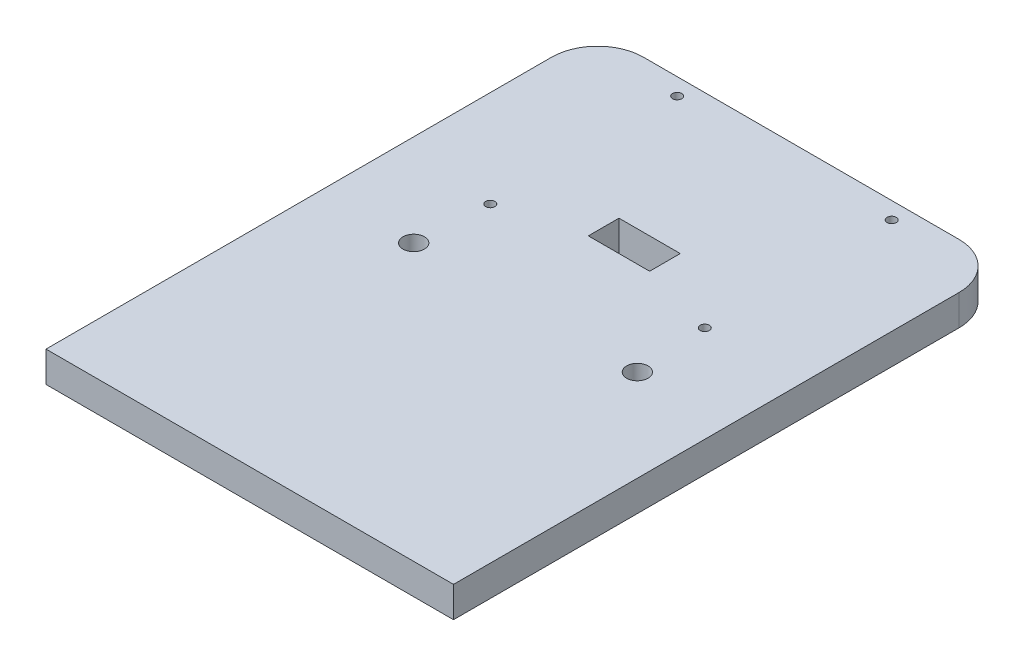
from build123d import *

# Parameters (mm, degrees)
SKETCH1_R           = 3.5
SKETCH1_R_2         = 1.5
SKETCH1_W           = 20
SKETCH1_H           = 10
BOSS_EXTRUDE1_DEPTH = 10


with BuildPart() as part:
    # Sketch1 → Boss-Extrude1 (new body)
    with BuildSketch(Plane(origin=(0, 0, 0), x_dir=(1, 0, 0), z_dir=(0, 1, 0))):
        Polygon((0.049612108, 0.067144207), (-66.5, -90), (66.5, -90), align=None)
        with BuildLine():
            Line((-66.5, 75), (-66.5, -90))
            Line((-66.5, -90), (0.049612108, 0.067144207))
            Line((0.049612108, 0.067144207), (-62.643246745, 85.041317243))
            ThreePointArc((-62.643246745, 85.041317243), (-65.502655126, 80.378257098), (-66.5, 75))
        make_face()
        with Locations((-36.5, 0)):
            Circle(SKETCH1_R, mode=Mode.SUBTRACT)
        with Locations((-35, 23.5)):
            Circle(SKETCH1_R_2, mode=Mode.SUBTRACT)
        with BuildLine():
            Line((62.748695437, 84.923046456), (0.049612108, 0.067144207))
            Line((0.049612108, 0.067144207), (66.5, -90))
            Line((66.5, -90), (66.5, 75))
            ThreePointArc((66.5, 75), (65.530866537, 80.304223244), (62.748695437, 84.923046456))
        make_face()
        with Locations((36.5, 0)):
            Circle(SKETCH1_R, mode=Mode.SUBTRACT)
        with Locations((35, 23.5)):
            Circle(SKETCH1_R_2, mode=Mode.SUBTRACT)
        with BuildLine():
            Line((-62.643246745, 85.041317243), (0.049612108, 0.067144207))
            Line((0.049612108, 0.067144207), (62.748695437, 84.923046456))
            ThreePointArc((62.748695437, 84.923046456), (57.670668649, 88.671973099), (51.5, 90))
            Line((51.5, 90), (-51.5, 90))
            ThreePointArc((-51.5, 90), (-57.598370329, 88.704374459), (-62.643246745, 85.041317243))
        make_face()
        with Locations((-35, 84.5)):
            Circle(SKETCH1_R_2, mode=Mode.SUBTRACT)
        with Locations((0, 35.5)):
            Rectangle(SKETCH1_W, SKETCH1_H, mode=Mode.SUBTRACT)
        with Locations((35, 84.5)):
            Circle(SKETCH1_R_2, mode=Mode.SUBTRACT)
    extrude(amount=BOSS_EXTRUDE1_DEPTH)


solid = part.part
